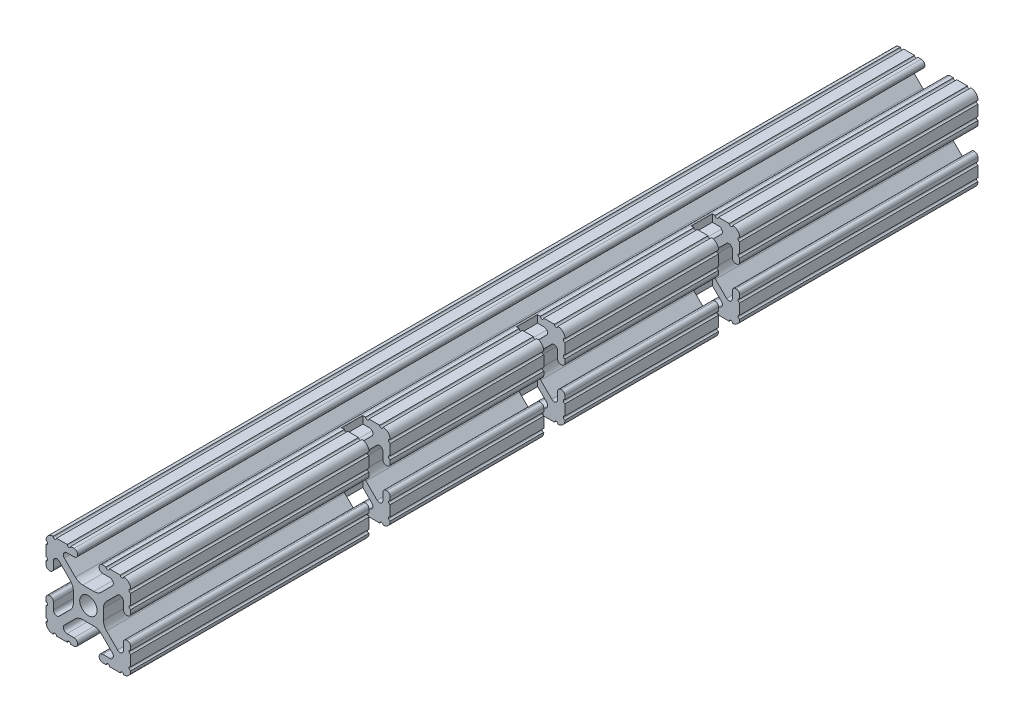
from build123d import *

# Parameters (mm, degrees)
SKETCH1_R               = 2.6035
BOSS_EXTRUDE1_DEPTH     = 127
SKETCH3_W               = 12.115886191
SKETCH3_H               = 6.35
CUT_EXTRUDE2_DEPTH      = 1
CUT_EXTRUDE2_DEPTH_BACK = 26.4


with BuildPart() as part:
    # Sketch1 → Boss-Extrude1 (new body, symmetric)
    with BuildSketch(Plane.XY):
        with BuildLine():
            Line((-7.179650497, -8.645192506), (-3.952270251, -5.423690499))
            ThreePointArc((-3.952270251, -5.423690499), (-2.922936451, -4.736929036), (-1.709253557, -4.4958))
            Line((-1.709253557, -4.4958), (1.709253557, -4.4958))
            ThreePointArc((1.709253557, -4.4958), (2.922936451, -4.736929036), (3.952270251, -5.423690499))
            Line((3.952270251, -5.423690499), (7.179650497, -8.645192506))
            ThreePointArc((7.179650497, -8.645192506), (7.41473083, -9.822813117), (6.416408329, -10.4902))
            Line((6.416408329, -10.4902), (4.287512407, -10.4902))
            ThreePointArc((4.287512407, -10.4902), (3.54574862, -10.79744862), (3.2385, -11.539212407))
            Line((3.2385, -11.539212407), (3.2385, -11.650987593))
            ThreePointArc((3.2385, -11.650987593), (3.54574862, -12.39275138), (4.287512407, -12.7))
            Line((4.287512407, -12.7), (5.317126718, -12.7))
            ThreePointArc((5.317126718, -12.7), (5.825126718, -12.192), (6.333126718, -12.7))
            Line((6.333126718, -12.7), (9.550443118, -12.7))
            ThreePointArc((9.550443118, -12.7), (10.058366869, -12.192000006), (10.566443095, -12.699847501))
            ThreePointArc((10.566443095, -12.699847501), (12.082537762, -12.08250727), (12.699846982, -10.566399977))
            ThreePointArc((12.699846982, -10.566399977), (12.192000006, -10.058323491), (12.7, -9.5504))
            Line((12.7, -9.5504), (12.7, -6.3330836))
            ThreePointArc((12.7, -6.3330836), (12.192, -5.8250836), (12.7, -5.3170836))
            Line((12.7, -5.3170836), (12.7, -4.287469289))
            ThreePointArc((12.7, -4.287469289), (12.39275138, -3.545705502), (11.650987593, -3.238456882))
            Line((11.650987593, -3.238456882), (11.539212407, -3.238456882))
            ThreePointArc((11.539212407, -3.238456882), (10.79744862, -3.545705502), (10.4902, -4.287469289))
            Line((10.4902, -4.287469289), (10.4902, -6.402089023))
            ThreePointArc((10.4902, -6.402089023), (9.856505071, -7.351067942), (8.737131347, -7.129408934))
            Line((8.737131347, -7.129408934), (5.441005833, -3.840816462))
            ThreePointArc((5.441005833, -3.840816462), (4.750877967, -2.809883091), (4.5085, -1.593185507))
            Line((4.5085, -1.593185507), (4.5085, 1.593185507))
            ThreePointArc((4.5085, 1.593185507), (4.750877967, 2.809883091), (5.441005833, 3.840816462))
            Line((5.441005833, 3.840816462), (8.737131347, 7.129408934))
            ThreePointArc((8.737131347, 7.129408934), (9.856505071, 7.351067942), (10.4902, 6.402089023))
            Line((10.4902, 6.402089023), (10.4902, 4.287469289))
            ThreePointArc((10.4902, 4.287469289), (10.79744862, 3.545705502), (11.539212407, 3.238456882))
            Line((11.539212407, 3.238456882), (11.650987593, 3.238456882))
            ThreePointArc((11.650987593, 3.238456882), (12.39275138, 3.545705502), (12.7, 4.287469289))
            Line((12.7, 4.287469289), (12.7, 5.3170836))
            ThreePointArc((12.7, 5.3170836), (12.192, 5.8250836), (12.7, 6.3330836))
            Line((12.7, 6.3330836), (12.7, 9.5504))
            ThreePointArc((12.7, 9.5504), (12.192000006, 10.058323491), (12.699846982, 10.566399977))
            ThreePointArc((12.699846982, 10.566399977), (12.082537762, 12.08250727), (10.566443095, 12.699847501))
            ThreePointArc((10.566443095, 12.699847501), (10.058366869, 12.192000006), (9.550443118, 12.7))
            Line((9.550443118, 12.7), (6.333126718, 12.7))
            ThreePointArc((6.333126718, 12.7), (5.825126718, 12.192), (5.317126718, 12.7))
            Line((5.317126718, 12.7), (4.287512407, 12.7))
            ThreePointArc((4.287512407, 12.7), (3.54574862, 12.39275138), (3.2385, 11.650987593))
            Line((3.2385, 11.650987593), (3.2385, 11.539212407))
            ThreePointArc((3.2385, 11.539212407), (3.54574862, 10.79744862), (4.287512407, 10.4902))
            Line((4.287512407, 10.4902), (6.476788598, 10.4902))
            ThreePointArc((6.476788598, 10.4902), (7.432222385, 9.85140422), (7.207036008, 8.724370562))
            Line((7.207036008, 8.724370562), (3.898272566, 5.423169045))
            ThreePointArc((3.898272566, 5.423169045), (2.869120213, 4.736787962), (1.655778399, 4.4958))
            Line((1.655778399, 4.4958), (-1.655778399, 4.4958))
            ThreePointArc((-1.655778399, 4.4958), (-2.869120213, 4.736787962), (-3.898272566, 5.423169045))
            Line((-3.898272566, 5.423169045), (-7.207036008, 8.724370562))
            ThreePointArc((-7.207036008, 8.724370562), (-7.432222385, 9.85140422), (-6.476788598, 10.4902))
            Line((-6.476788598, 10.4902), (-4.287512407, 10.4902))
            ThreePointArc((-4.287512407, 10.4902), (-3.54574862, 10.79744862), (-3.2385, 11.539212407))
            Line((-3.2385, 11.539212407), (-3.2385, 11.650987593))
            ThreePointArc((-3.2385, 11.650987593), (-3.54574862, 12.39275138), (-4.287512407, 12.7))
            Line((-4.287512407, 12.7), (-5.317126718, 12.7))
            ThreePointArc((-5.317126718, 12.7), (-5.825126718, 12.192), (-6.333126718, 12.7))
            Line((-6.333126718, 12.7), (-9.550443118, 12.7))
            ThreePointArc((-9.550443118, 12.7), (-10.058366869, 12.192000006), (-10.566443095, 12.699847501))
            ThreePointArc((-10.566443095, 12.699847501), (-12.082537762, 12.08250727), (-12.699846982, 10.566399977))
            ThreePointArc((-12.699846982, 10.566399977), (-12.192000006, 10.058323491), (-12.7, 9.5504))
            Line((-12.7, 9.5504), (-12.7, 6.3330836))
            ThreePointArc((-12.7, 6.3330836), (-12.192, 5.8250836), (-12.7, 5.3170836))
            Line((-12.7, 5.3170836), (-12.7, 4.287469289))
            ThreePointArc((-12.7, 4.287469289), (-12.39275138, 3.545705502), (-11.650987593, 3.238456882))
            Line((-11.650987593, 3.238456882), (-11.539212407, 3.238456882))
            ThreePointArc((-11.539212407, 3.238456882), (-10.79744862, 3.545705502), (-10.4902, 4.287469289))
            Line((-10.4902, 4.287469289), (-10.4902, 6.402089023))
            ThreePointArc((-10.4902, 6.402089023), (-9.856505071, 7.351067942), (-8.737131347, 7.129408934))
            Line((-8.737131347, 7.129408934), (-5.441005833, 3.840816462))
            ThreePointArc((-5.441005833, 3.840816462), (-4.750877967, 2.809883091), (-4.5085, 1.593185507))
            Line((-4.5085, 1.593185507), (-4.5085, -1.593185507))
            ThreePointArc((-4.5085, -1.593185507), (-4.750877967, -2.809883091), (-5.441005833, -3.840816462))
            Line((-5.441005833, -3.840816462), (-8.737131347, -7.129408934))
            ThreePointArc((-8.737131347, -7.129408934), (-9.856505071, -7.351067942), (-10.4902, -6.402089023))
            Line((-10.4902, -6.402089023), (-10.4902, -4.287469289))
            ThreePointArc((-10.4902, -4.287469289), (-10.79744862, -3.545705502), (-11.539212407, -3.238456882))
            Line((-11.539212407, -3.238456882), (-11.650987593, -3.238456882))
            ThreePointArc((-11.650987593, -3.238456882), (-12.39275138, -3.545705502), (-12.7, -4.287469289))
            Line((-12.7, -4.287469289), (-12.7, -5.3170836))
            ThreePointArc((-12.7, -5.3170836), (-12.192, -5.8250836), (-12.7, -6.3330836))
            Line((-12.7, -6.3330836), (-12.7, -9.5504))
            ThreePointArc((-12.7, -9.5504), (-12.192000006, -10.058323491), (-12.699846982, -10.566399977))
            ThreePointArc((-12.699846982, -10.566399977), (-12.082537762, -12.08250727), (-10.566443095, -12.699847501))
            ThreePointArc((-10.566443095, -12.699847501), (-10.058366869, -12.192000006), (-9.550443118, -12.7))
            Line((-9.550443118, -12.7), (-6.333126718, -12.7))
            ThreePointArc((-6.333126718, -12.7), (-5.825126718, -12.192), (-5.317126718, -12.7))
            Line((-5.317126718, -12.7), (-4.287512407, -12.7))
            ThreePointArc((-4.287512407, -12.7), (-3.54574862, -12.39275138), (-3.2385, -11.650987593))
            Line((-3.2385, -11.650987593), (-3.2385, -11.539212407))
            ThreePointArc((-3.2385, -11.539212407), (-3.54574862, -10.79744862), (-4.287512407, -10.4902))
            Line((-4.287512407, -10.4902), (-6.416408329, -10.4902))
            ThreePointArc((-6.416408329, -10.4902), (-7.41473083, -9.822813117), (-7.179650497, -8.645192506))
        make_face()
        Circle(SKETCH1_R, mode=Mode.SUBTRACT)
    extrude(amount=BOSS_EXTRUDE1_DEPTH, both=True)

    # Sketch3 → Cut-Extrude2 (cut, two sides)
    with BuildSketch(Plane(origin=(0, 12.7, 0), x_dir=(1, 0, 0), z_dir=(0, 1, 0))) as cut_extrude2_sk:
        with Locations((10.566443096, 0)):
            Rectangle(SKETCH3_W, SKETCH3_H)
        with Locations((10.566443096, 52.3875)):
            Rectangle(SKETCH3_W, SKETCH3_H)
        with Locations((10.566443096, -52.3875)):
            Rectangle(SKETCH3_W, SKETCH3_H)
    extrude(amount=CUT_EXTRUDE2_DEPTH, mode=Mode.SUBTRACT)
    extrude(cut_extrude2_sk.sketch, amount=-CUT_EXTRUDE2_DEPTH_BACK, mode=Mode.SUBTRACT)


solid = part.part
